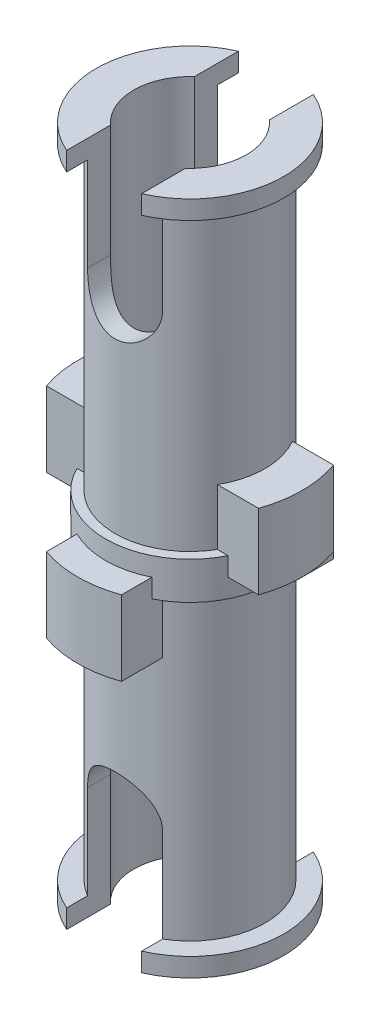
from build123d import *

# Parameters (mm, degrees)
SKETCH3_W               = 6
SKETCH3_H               = 2
BOSS_EXTRUDE4_DEPTH     = 1
SKETCH4_W               = 6
SKETCH4_H               = 2
BOSS_EXTRUDE5_DEPTH     = 1
CUT_EXTRUDE2_DEPTH      = 4
CUT_EXTRUDE2_DEPTH_BACK = 4
SKETCH6_R               = 1.5
CUT_EXTRUDE3_DEPTH      = 18
SKETCH7_OUTSIDE_W       = 11.98
SKETCH7_OUTSIDE_H       = 11.98
SKETCH7_OUTSIDE_R       = 3
CUT_EXTRUDE4_DEPTH      = 10.0000001
CUT_EXTRUDE4_DEPTH_BACK = 10.0000001


with BuildPart() as part:
    # Sketch1 → Revolve5 (revolve)
    with BuildSketch(Plane.XY):
        Polygon((0, 9), (-2.5, 9), (-2.5, 8.5), (-2, 8.5), (-2, 0.5), (-2.25, 0.5), (-2.25, -0.5), (-2, -0.5), (-2, -8.5), (-2.5, -8.5), (-2.5, -9), (0, -9), align=None)
    revolve(axis=Axis((0, 9, 0), (0, -1, 0)))

    # Sketch3 → Boss-Extrude4 (add, symmetric)
    with BuildSketch(Plane.XY):
        with Locations((0, 1)):
            Rectangle(SKETCH3_W, SKETCH3_H)
    extrude(amount=BOSS_EXTRUDE4_DEPTH, both=True)

    # Sketch4 → Boss-Extrude5 (add, symmetric)
    with BuildSketch(Plane(origin=(0, 0, 0), x_dir=(0, 0, -1), z_dir=(1, 0, 0))):
        with Locations((0, -1)):
            Rectangle(SKETCH4_W, SKETCH4_H)
    extrude(amount=BOSS_EXTRUDE5_DEPTH, both=True)

    # Sketch5 → Cut-Extrude2 (cut, two sides)
    with BuildSketch(Plane.XY) as cut_extrude2_sk:
        with BuildLine():
            Line((-1, 9), (-1, 6))
            ThreePointArc((-1, 6), (0, 5), (1, 6))
            Line((1, 6), (1, 9))
            Line((1, 9), (-1, 9))
        make_face()
        with BuildLine():
            Line((-1, -9), (-1, -6))
            ThreePointArc((-1, -6), (0, -5), (1, -6))
            Line((1, -6), (1, -9))
            Line((1, -9), (-1, -9))
        make_face()
    extrude(amount=CUT_EXTRUDE2_DEPTH, mode=Mode.SUBTRACT)
    extrude(cut_extrude2_sk.sketch, amount=-CUT_EXTRUDE2_DEPTH_BACK, mode=Mode.SUBTRACT)

    # Sketch6 → Cut-Extrude3 (cut)
    with BuildSketch(Plane(origin=(0, 9, 0), x_dir=(1, 0, 0), z_dir=(0, 1, 0))):
        Circle(SKETCH6_R)
    extrude(amount=-CUT_EXTRUDE3_DEPTH, mode=Mode.SUBTRACT)

    # Sketch7 outside → Cut-Extrude4 (cut, two sides)
    with BuildSketch(Plane(origin=(0, 0, 0), x_dir=(1, 0, 0), z_dir=(0, 1, 0))) as cut_extrude4_sk:
        Rectangle(SKETCH7_OUTSIDE_W, SKETCH7_OUTSIDE_H)
        Circle(SKETCH7_OUTSIDE_R, mode=Mode.SUBTRACT)
    extrude(amount=CUT_EXTRUDE4_DEPTH, mode=Mode.SUBTRACT)
    extrude(cut_extrude4_sk.sketch, amount=-CUT_EXTRUDE4_DEPTH_BACK, mode=Mode.SUBTRACT)


solid = part.part
